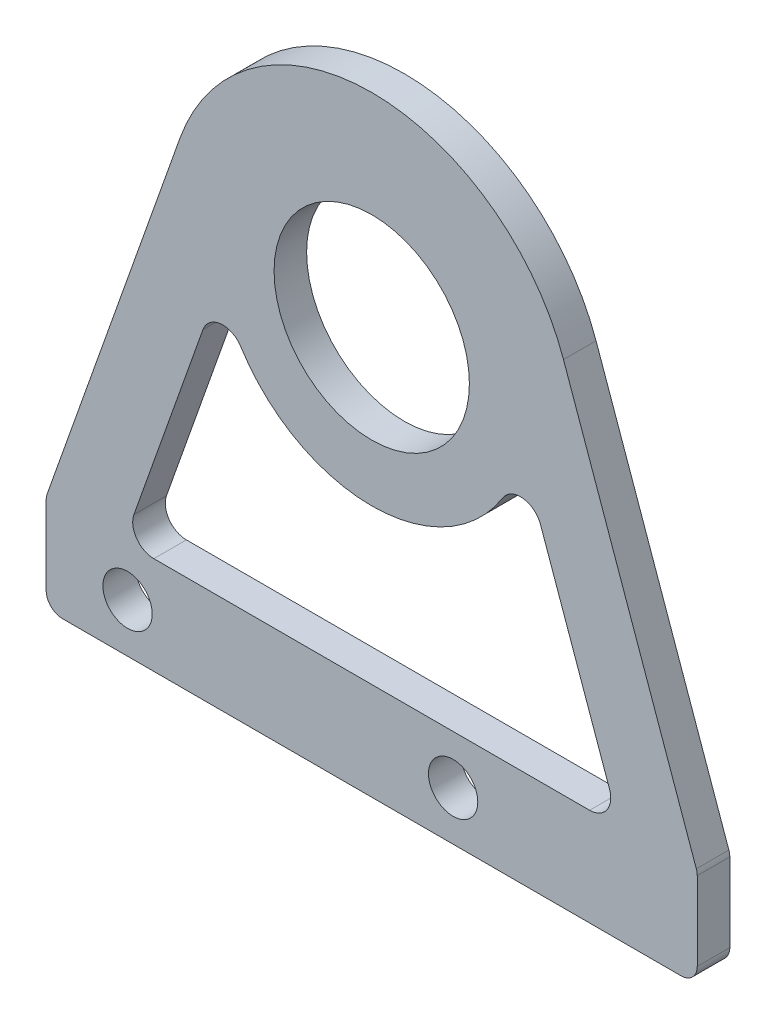
from build123d import *

# Parameters (mm, degrees)
SKETCH_1_R          = 6
EXTRUDE_1_DEPTH     = 2
FILLET_1_R          = 1
SKETCH_2_R          = 1.515
CUT_EXTRUDE_1_DEPTH = 10
CUT_EXTRUDE_2_DEPTH = 10
FILLET_2_R          = 1.3


with BuildPart() as part:
    # 草图1 → 凸台-拉伸1 (new body)
    with BuildSketch(Plane.XY):
        with BuildLine():
            Line((-20, -25), (20, -25))
            Line((20, -25), (20, -19))
            Line((20, -19), (11.781235871, 4.177616707))
            ThreePointArc((11.781235871, 4.177616707), (0, 12.5), (-11.781235871, 4.177616707))
            Line((-11.781235871, 4.177616707), (-20, -19))
            Line((-20, -19), (-20, -25))
        make_face()
        Circle(SKETCH_1_R, mode=Mode.SUBTRACT)
    extrude(amount=EXTRUDE_1_DEPTH)

    # 圆角1
    fillet_1_edges = [part.edges().sort_by_distance(p)[0] for p in [
        (20, -19, 1),
        (20, -25, 1),
        (-20, -25, 1),
        (-20, -19, 1),
    ]]
    fillet(fillet_1_edges, radius=FILLET_1_R)

    # 草图2 → 切除-拉伸1 (cut)
    with BuildSketch(Plane(origin=(0, 0, 0), x_dir=(-1, 0, 0), z_dir=(0, 0, -1))):
        with Locations((15, -22)):
            Circle(SKETCH_2_R)
        with Locations((-5, -22)):
            Circle(SKETCH_2_R)
    extrude(amount=-CUT_EXTRUDE_1_DEPTH, mode=Mode.SUBTRACT)

    # 草图3 → 切除-拉伸2 (cut)
    with BuildSketch(Plane(origin=(0, 0, 0), x_dir=(-1, 0, 0), z_dir=(0, 0, -1))):
        with BuildLine():
            Line((-9.252304266, -2.155195065), (-15.225458465, -19))
            Line((-15.225458465, -19), (15.225458465, -19))
            Line((15.225458465, -19), (9.252304266, -2.155195065))
            ThreePointArc((9.252304266, -2.155195065), (0, -9.5), (-9.252304266, -2.155195065))
        make_face()
    extrude(amount=-CUT_EXTRUDE_2_DEPTH, mode=Mode.SUBTRACT)

    # 圆角2
    fillet_2_edges = [part.edges().sort_by_distance(p)[0] for p in [
        (9.252304266, -2.155195065, 1),
        (-9.252304266, -2.155195065, 1),
        (-15.225458465, -19, 1),
        (15.225458465, -19, 1),
    ]]
    fillet(fillet_2_edges, radius=FILLET_2_R)


solid = part.part
